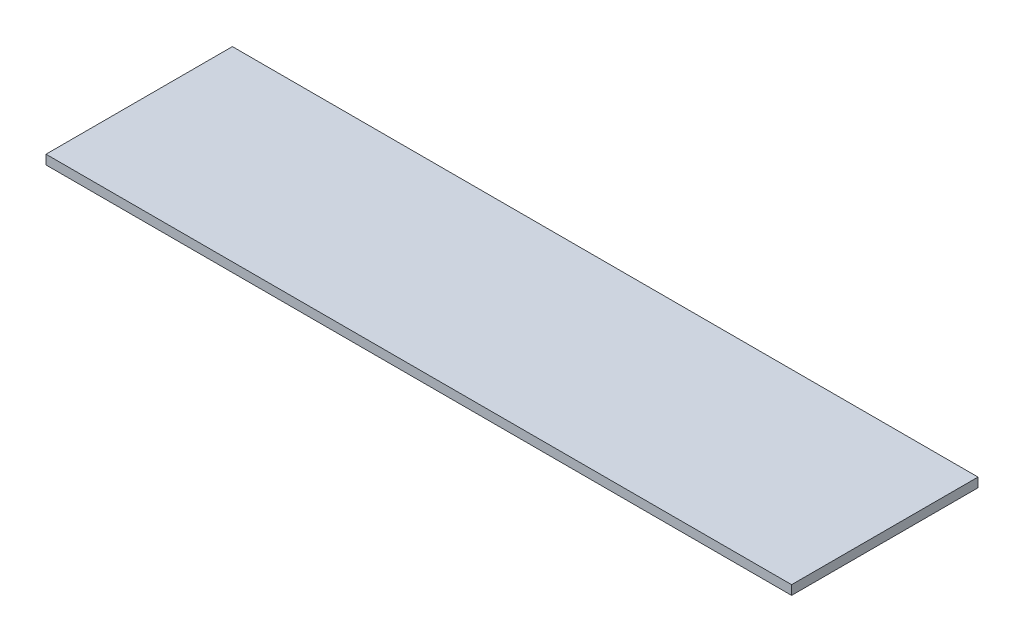
from build123d import *

# Parameters (mm, degrees)
SKETCH1_W           = 80
SKETCH1_H           = 20
BOSS_EXTRUDE1_DEPTH = 1


with BuildPart() as part:
    # Sketch1 → Boss-Extrude1 (new body)
    with BuildSketch(Plane(origin=(0, 0, 0), x_dir=(1, 0, 0), z_dir=(0, 1, 0))):
        Rectangle(SKETCH1_W, SKETCH1_H)
    extrude(amount=BOSS_EXTRUDE1_DEPTH)


solid = part.part
